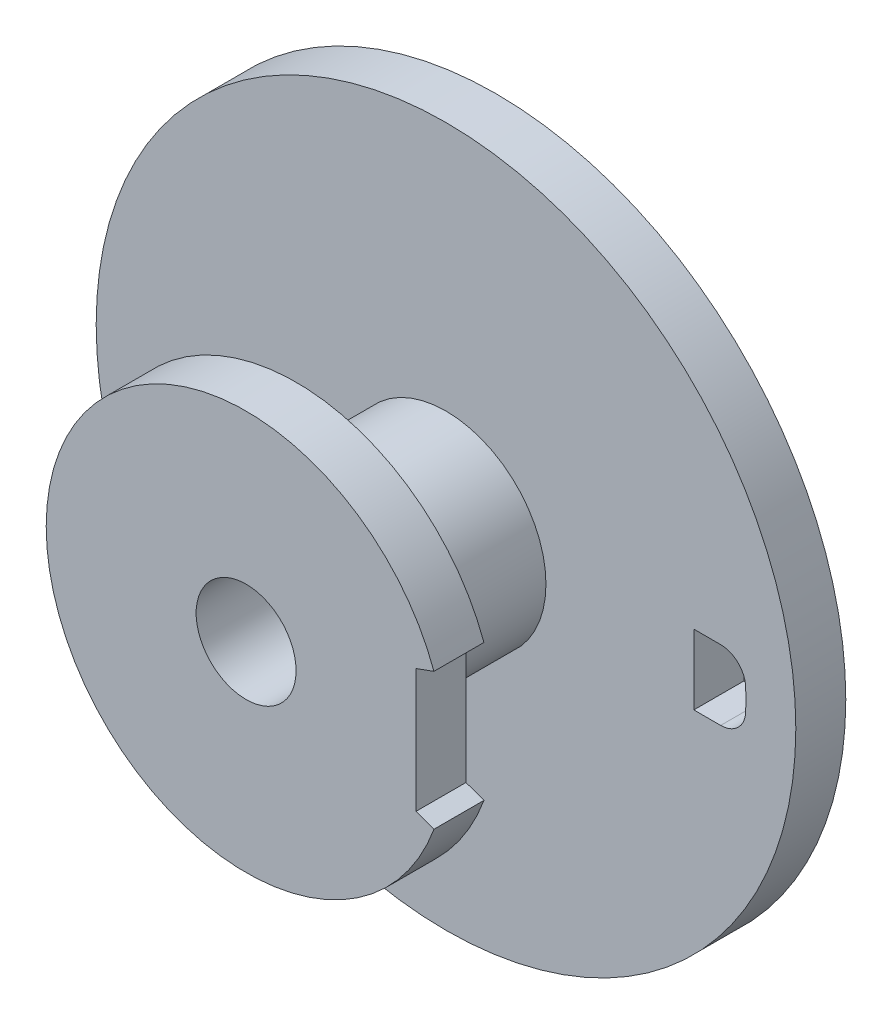
from build123d import *

# Parameters (mm, degrees)
CROQUIS1_R              = 0.5
CROQUIS1_R_2            = 0.25
SALIENTE_EXTRUIR1_DEPTH = 0.75
CROQUIS2_R              = 0.25
SALIENTE_EXTRUIR2_DEPTH = 0.25
CROQUIS3_R              = 1.75
CROQUIS3_R_2            = 0.25
SALIENTE_EXTRUIR3_DEPTH = 0.25
CORTAR_EXTRUIR1_REACH   = 3.25


with BuildPart() as part:
    # Croquis1 → Saliente-Extruir1 (new body)
    with BuildSketch(Plane.XY):
        Circle(CROQUIS1_R)
        Circle(CROQUIS1_R_2, mode=Mode.SUBTRACT)
    extrude(amount=-SALIENTE_EXTRUIR1_DEPTH)

    # Croquis2 → Saliente-Extruir2 (add)
    with BuildSketch(Plane.XY):
        with BuildLine():
            Line((0.85, 0.309374699), (0.85, -0.309374699))
            Line((0.85, -0.309374699), (0.939692621, -0.342020143))
            ThreePointArc((0.939692621, -0.342020143), (0.707106781, -0.707106781), (0.342020143, -0.939692621))
            ThreePointArc((0.342020143, -0.939692621), (-0.906307787, 0.422618262), (0.939692621, 0.342020143))
            Line((0.939692621, 0.342020143), (0.85, 0.309374699))
        make_face()
        Circle(CROQUIS2_R, mode=Mode.SUBTRACT)
    extrude(amount=SALIENTE_EXTRUIR2_DEPTH)

    # Croquis3 → Saliente-Extruir3 (add)
    with BuildSketch(Plane(origin=(0, 0, -0.75), x_dir=(-1, 0, 0), z_dir=(0, 0, -1))):
        Circle(CROQUIS3_R)
        Circle(CROQUIS3_R_2, mode=Mode.SUBTRACT)
    extrude(amount=SALIENTE_EXTRUIR3_DEPTH)

    # Croquis4 → Cortar-Extruir1 (cut, up to next)
    with BuildSketch(Plane(origin=(0, 0, -1), x_dir=(-1, 0, 0), z_dir=(0, 0, -1)), mode=Mode.PRIVATE) as cortar_extruir1_sk1:
        with BuildLine():
            Line((-1.374090608, 0.175), (-1.239756692, 0.175))
            Line((-1.239756692, 0.175), (-1.239756692, -0.175))
            Line((-1.239756692, -0.175), (-1.374090608, -0.175))
            ThreePointArc((-1.374090608, -0.175), (-1.460857014, -0.139981059), (-1.499007936, -0.054545455))
            ThreePointArc((-1.499007936, -0.054545455), (-1.5, 0), (-1.499007936, 0.054545455))
            ThreePointArc((-1.499007936, 0.054545455), (-1.460857014, 0.139981059), (-1.374090608, 0.175))
        make_face()
    cortar_extruir1_tool1 = extrude(cortar_extruir1_sk1.sketch, amount=-CORTAR_EXTRUIR1_REACH, mode=Mode.PRIVATE) & part.part
    add(cortar_extruir1_tool1.solids().sort_by_distance((1.361411, 0, -1))[0], mode=Mode.SUBTRACT)


solid = part.part
